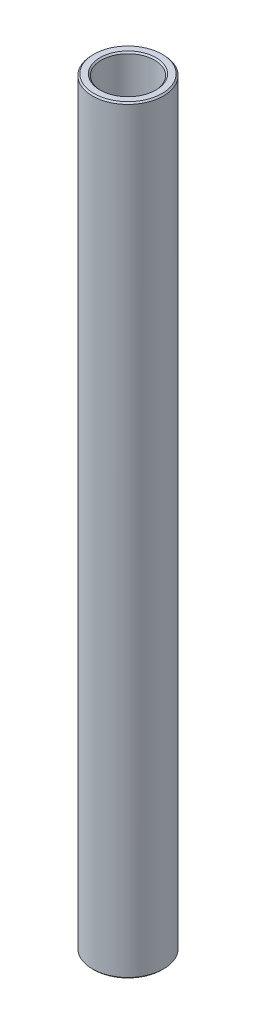
from build123d import *

# Parameters (mm, degrees)
SKETCH1_W     = 1.5875
SKETCH1_H     = 135.716645
CHAMFER1_SIZE = 0.254


with BuildPart() as part:
    # Sketch1 → Revolve1 (revolve)
    with BuildSketch(Plane.XY):
        with Locations((5.55625, 0)):
            Rectangle(SKETCH1_W, SKETCH1_H)
    revolve(axis=Axis((0, 11.60859375, 0), (0, -1, 0)))

    # Chamfer1
    chamfer1_edges = [part.edges().sort_by_distance(p)[0] for p in [
        (-4.7625, -67.8583225, 0),
        (-6.35, -67.8583225, 0),
        (-6.35, 67.8583225, 0),
        (-4.7625, 67.8583225, 0),
    ]]
    chamfer(chamfer1_edges, length=CHAMFER1_SIZE)


solid = part.part
